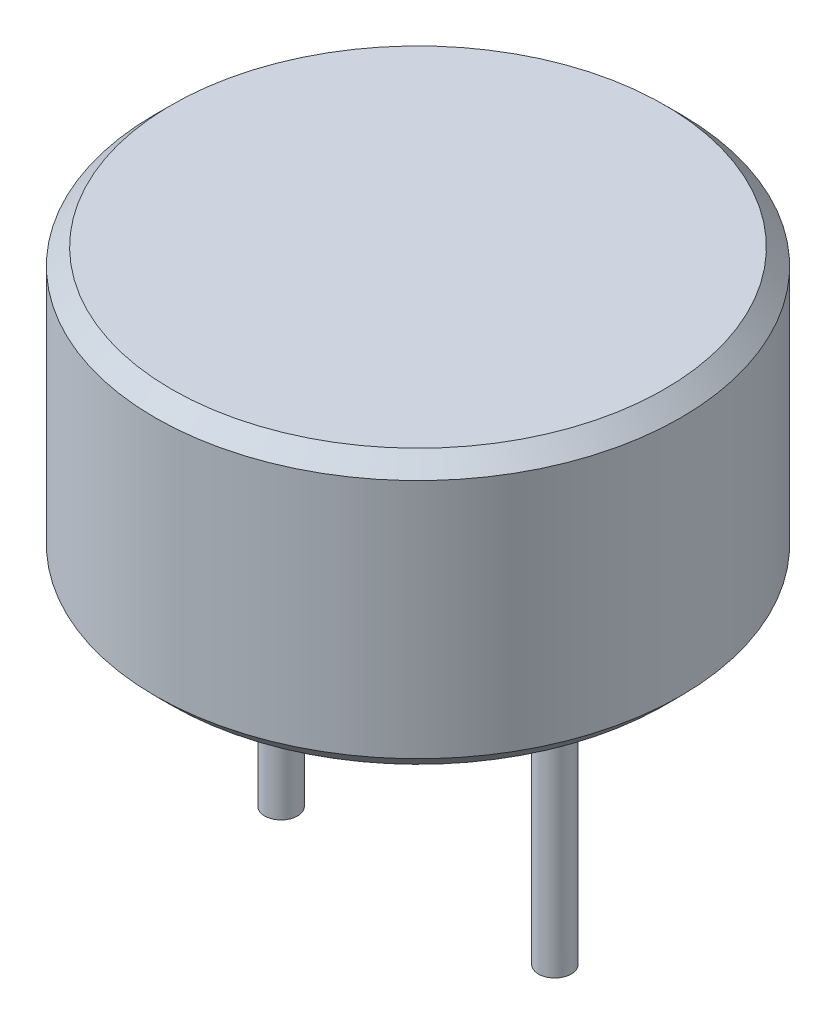
from build123d import *

# Parameters (mm, degrees)
SKETCH_1_R      = 4.8
EXTRUDE_1_DEPTH = 5
CHAMFER_1_SIZE  = 0.3
SKETCH_2_R      = 0.3
EXTRUDE_2_DEPTH = 5.1


with BuildPart() as part:
    # 草图1 → 凸台-拉伸1 (new body)
    with BuildSketch(Plane(origin=(0, 0, 0), x_dir=(1, 0, 0), z_dir=(0, 1, 0))):
        Circle(SKETCH_1_R)
    extrude(amount=EXTRUDE_1_DEPTH)

    # 倒角1
    chamfer_1_edges = [part.edges().sort_by_distance(p)[0] for p in [
        (-4.8, 0, 0),
        (-4.8, 5, 0),
    ]]
    chamfer(chamfer_1_edges, length=CHAMFER_1_SIZE)

    # 草图2 → 凸台-拉伸2 (add)
    with BuildSketch(Plane.XZ):
        with Locations((-2.5, 0)):
            Circle(SKETCH_2_R)
        with Locations((2.5, 0)):
            Circle(SKETCH_2_R)
    extrude(amount=EXTRUDE_2_DEPTH)


solid = part.part
